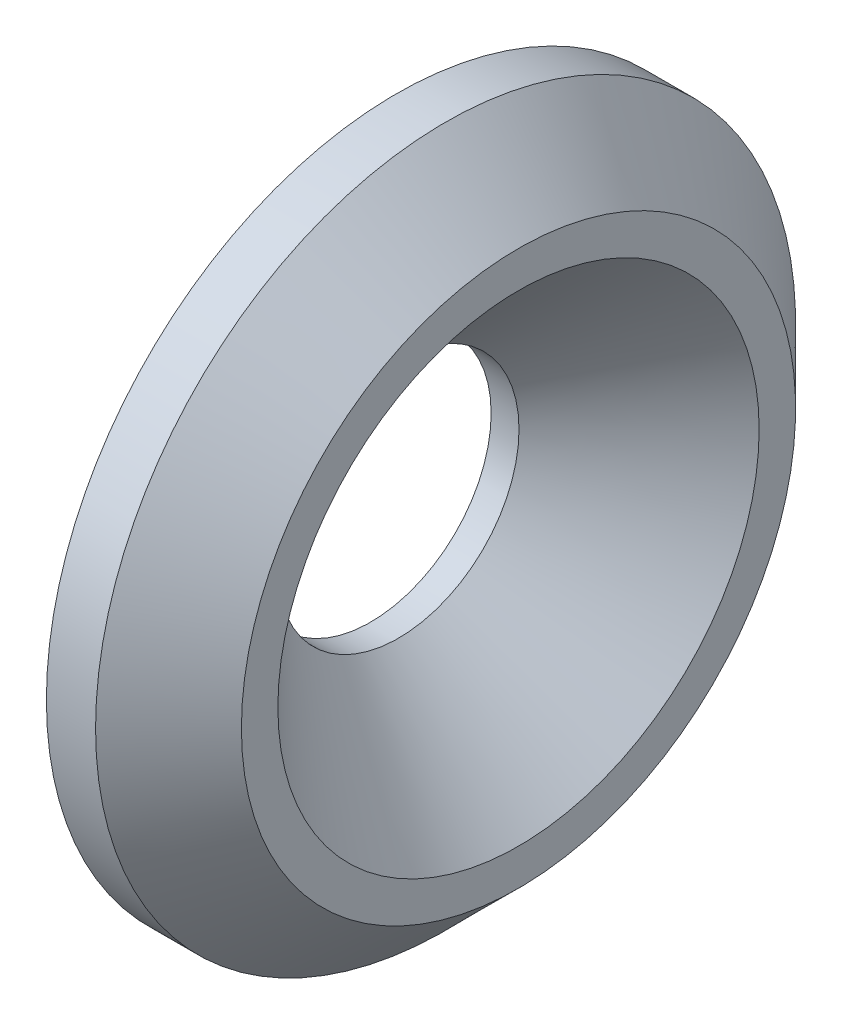
from build123d import *

# Parameters (mm, degrees)
HOLE1_D           = 10.5
HOLE1_DEPTH       = 16.51
HOLE1_CSINK_D     = 20.955
HOLE1_CSINK_ANGLE = 90
HOLE1_TIP         = 3.15451825


with BuildPart() as part:
    # Sketch1 → Revolve1 (revolve)
    with BuildSketch(Plane.XY):
        Polygon((461.35385273, 245.11), (461.35385273, 232.41), (467.794592233, 232.41), (467.794592233, 244.475), (464.619592233, 247.65), (462.47885273, 247.65), (462.47885273, 245.11), align=None)
    revolve(axis=Axis((443.287790535, 232.41, 0), (1, 0, 0)))

    # Hole1
    with Locations(Plane(origin=(467.794592233, 0, 0), x_dir=(0, 0, -1), z_dir=(1, 0, 0))):
        with Locations((0, 232.41)):
            CounterSinkHole(HOLE1_D / 2, HOLE1_CSINK_D / 2, depth=HOLE1_DEPTH, counter_sink_angle=HOLE1_CSINK_ANGLE)
            with Locations((0, 0, -(HOLE1_DEPTH + HOLE1_TIP / 2))):  # 118° drill point
                Cone(0, HOLE1_D / 2, HOLE1_TIP, mode=Mode.SUBTRACT)


solid = part.part
